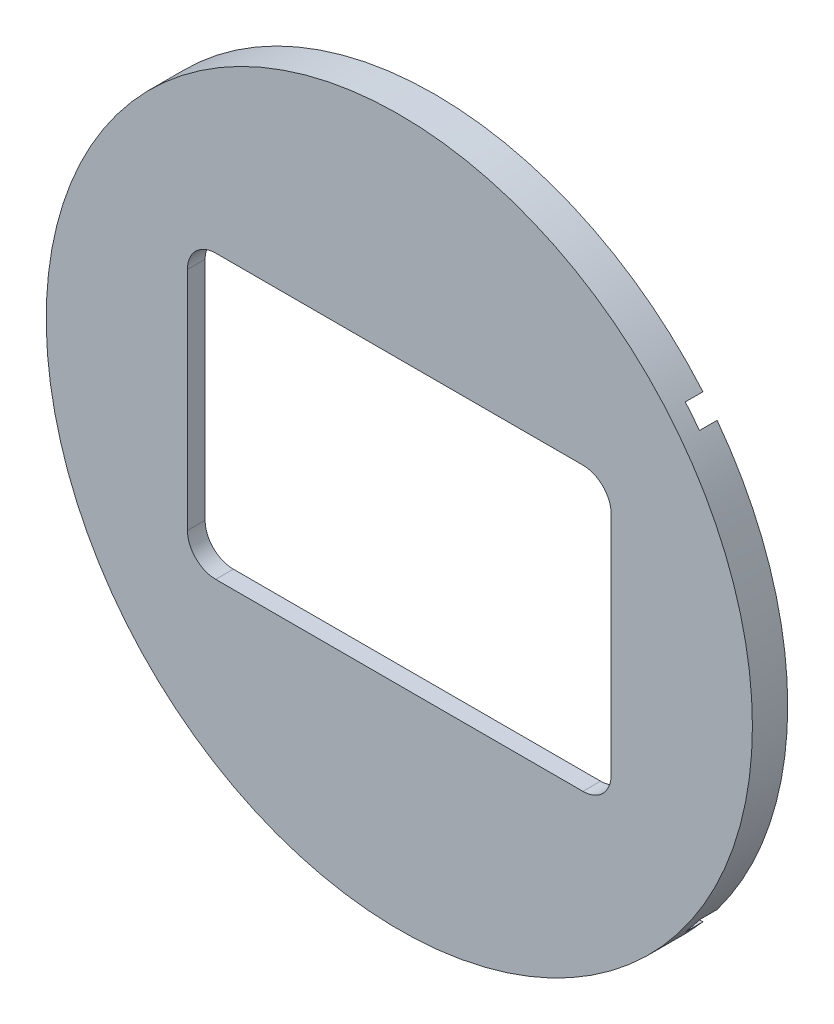
from build123d import *

# Parameters (mm, degrees)
SKETCH1_R           = 31.75
BOSS_EXTRUDE1_DEPTH = 1.5875
SKETCH3_W           = 50.8
SKETCH3_H           = 41.275
CUT_EXTRUDE1_DEPTH  = 1.5875
CUT_EXTRUDE2_REACH  = 3.587
SKETCH4_W           = 38.1
SKETCH4_H           = 25.4
FILLET3_R           = 2.54


with BuildPart() as part:
    # Sketch1 → Boss-Extrude1 (new body, symmetric)
    with BuildSketch(Plane.XY):
        Circle(SKETCH1_R)
    extrude(amount=BOSS_EXTRUDE1_DEPTH, both=True)

    # Sketch3 → Cut-Extrude1 (cut)
    with BuildSketch(Plane(origin=(0, 0, -1.5875), x_dir=(-1, 0, 0), z_dir=(0, 0, -1))):
        Rectangle(SKETCH3_W, SKETCH3_H)
    extrude(amount=-CUT_EXTRUDE1_DEPTH, mode=Mode.SUBTRACT)

    # Sketch4 → Cut-Extrude2 (cut, up to next)
    with BuildSketch(Plane(origin=(0, 0, 0), x_dir=(-1, 0, 0), z_dir=(0, 0, -1)), mode=Mode.PRIVATE) as cut_extrude2_sk1:
        Rectangle(SKETCH4_W, SKETCH4_H)
    cut_extrude2_tool1 = extrude(cut_extrude2_sk1.sketch, amount=-CUT_EXTRUDE2_REACH, mode=Mode.PRIVATE) & part.part
    add(cut_extrude2_tool1.solids().sort_by_distance((0, 0, 0))[0], mode=Mode.SUBTRACT)

    # Fillet3
    fillet3_edges = [part.edges().sort_by_distance(p)[0] for p in [
        (-19.05, 12.7, 0.79375),
        (-19.05, -12.7, 0.79375),
        (19.05, -12.7, 0.79375),
        (19.05, 12.7, 0.79375),
    ]]
    fillet(fillet3_edges, radius=FILLET3_R)


solid = part.part
